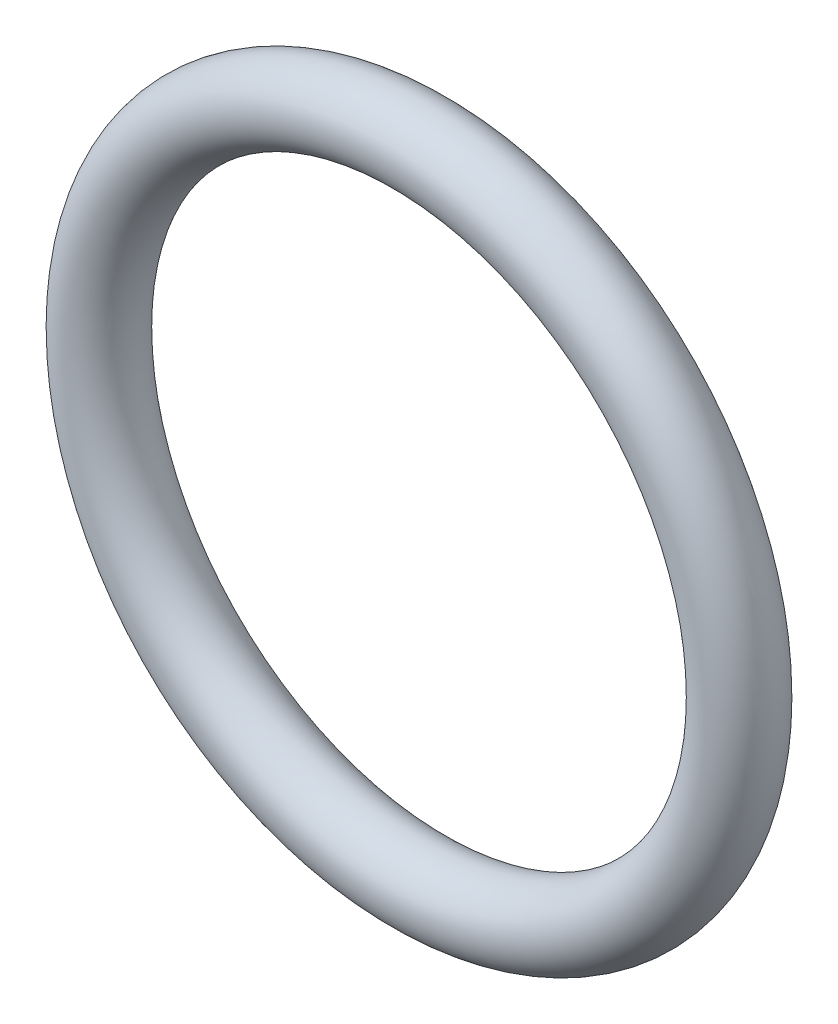
from build123d import *

# Parameters (mm, degrees)
ESQUISSE1_R = 1.75


with BuildPart() as part:
    # Esquisse1 → Révolution1 (revolve)
    with BuildSketch(Plane(origin=(0, 0, 0), x_dir=(1, 0, 0), z_dir=(0, 1, 0))):
        with Locations((-15, 0)):
            Circle(ESQUISSE1_R)
    revolve(axis=Axis((0, 0, 0), (0, 0, -1)))


solid = part.part
